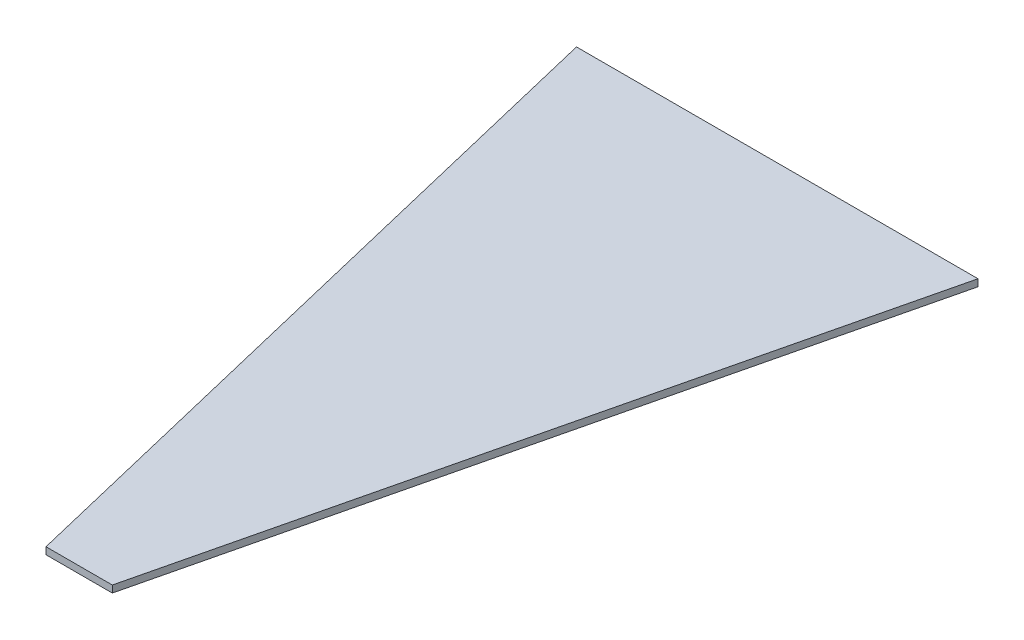
from build123d import *

# Parameters (mm, degrees)
BOSS_EXTRUDE1_DEPTH = 1


with BuildPart() as part:
    # Sketch1 → Boss-Extrude1 (new body)
    with BuildSketch(Plane(origin=(0, 0, 0), x_dir=(1, 0, 0), z_dir=(0, 1, 0))):
        Polygon((4.75, 0), (28.757875908, 100), (-28.757875908, 100), (-4.75, 0), align=None)
    extrude(amount=BOSS_EXTRUDE1_DEPTH)


solid = part.part
